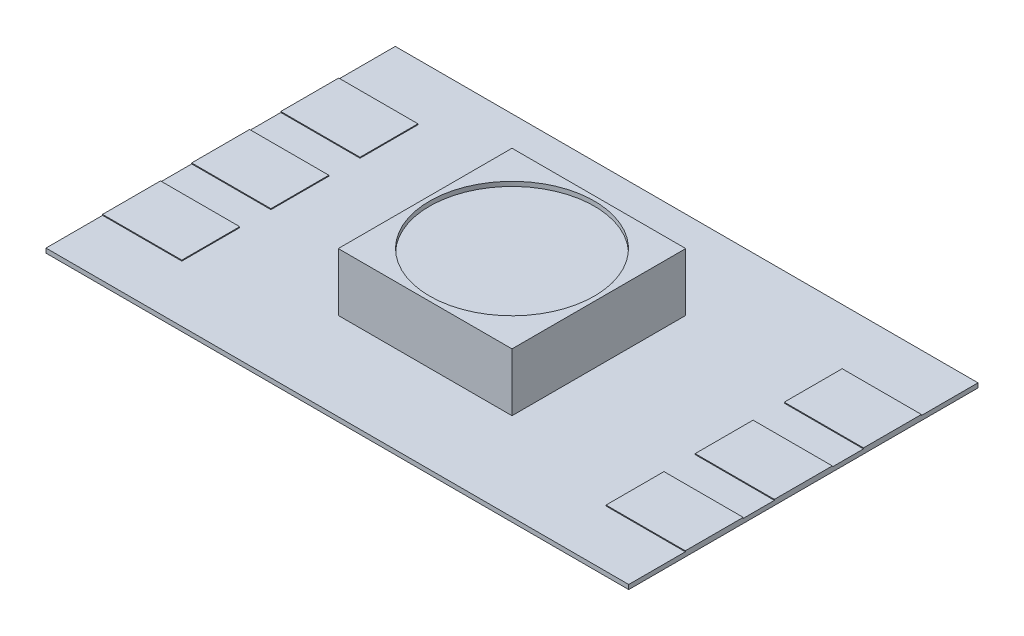
from build123d import *

# Parameters (mm, degrees)
SKETCH1_W           = 16.6116
SKETCH1_H           = 9.9568
BOSS_EXTRUDE1_DEPTH = 0.127
SKETCH3_W           = 4.953
SKETCH3_H           = 4.953
BOSS_EXTRUDE3_DEPTH = 1.651
SKETCH4_W           = 2.258810151
SKETCH4_H           = 1.651
BOSS_EXTRUDE4_DEPTH = 0.0254
SKETCH5_R           = 2.348345572
CUT_EXTRUDE1_DEPTH  = 0.127


with BuildPart() as part:
    # Sketch1 → Boss-Extrude1 (new body)
    with BuildSketch(Plane(origin=(0, 0, 0), x_dir=(1, 0, 0), z_dir=(0, 1, 0))):
        Rectangle(SKETCH1_W, SKETCH1_H)
    extrude(amount=BOSS_EXTRUDE1_DEPTH)

    # Sketch3 → Boss-Extrude3 (add)
    with BuildSketch(Plane(origin=(0, 0.127, 0), x_dir=(1, 0, 0), z_dir=(0, 1, 0))):
        Rectangle(SKETCH3_W, SKETCH3_H)
    extrude(amount=BOSS_EXTRUDE3_DEPTH)

    # Sketch4 → Boss-Extrude4 (add)
    with BuildSketch(Plane(origin=(0, 0.127, 0), x_dir=(1, 0, 0), z_dir=(0, 1, 0))):
        with Locations((-7.176394925, 0)):
            Rectangle(SKETCH4_W, SKETCH4_H)
        with Locations((-7.176394925, 2.54)):
            Rectangle(SKETCH4_W, SKETCH4_H)
        with Locations((-7.176394925, -2.54)):
            Rectangle(SKETCH4_W, SKETCH4_H)
        with Locations((7.176394925, -2.54)):
            Rectangle(SKETCH4_W, SKETCH4_H)
        with Locations((7.176394925, 0)):
            Rectangle(SKETCH4_W, SKETCH4_H)
        with Locations((7.176394925, 2.54)):
            Rectangle(SKETCH4_W, SKETCH4_H)
    extrude(amount=BOSS_EXTRUDE4_DEPTH)

    # Sketch5 → Cut-Extrude1 (cut)
    with BuildSketch(Plane(origin=(0, 1.778, 0), x_dir=(1, 0, 0), z_dir=(0, 1, 0))):
        Circle(SKETCH5_R)
    extrude(amount=-CUT_EXTRUDE1_DEPTH, mode=Mode.SUBTRACT)


solid = part.part
